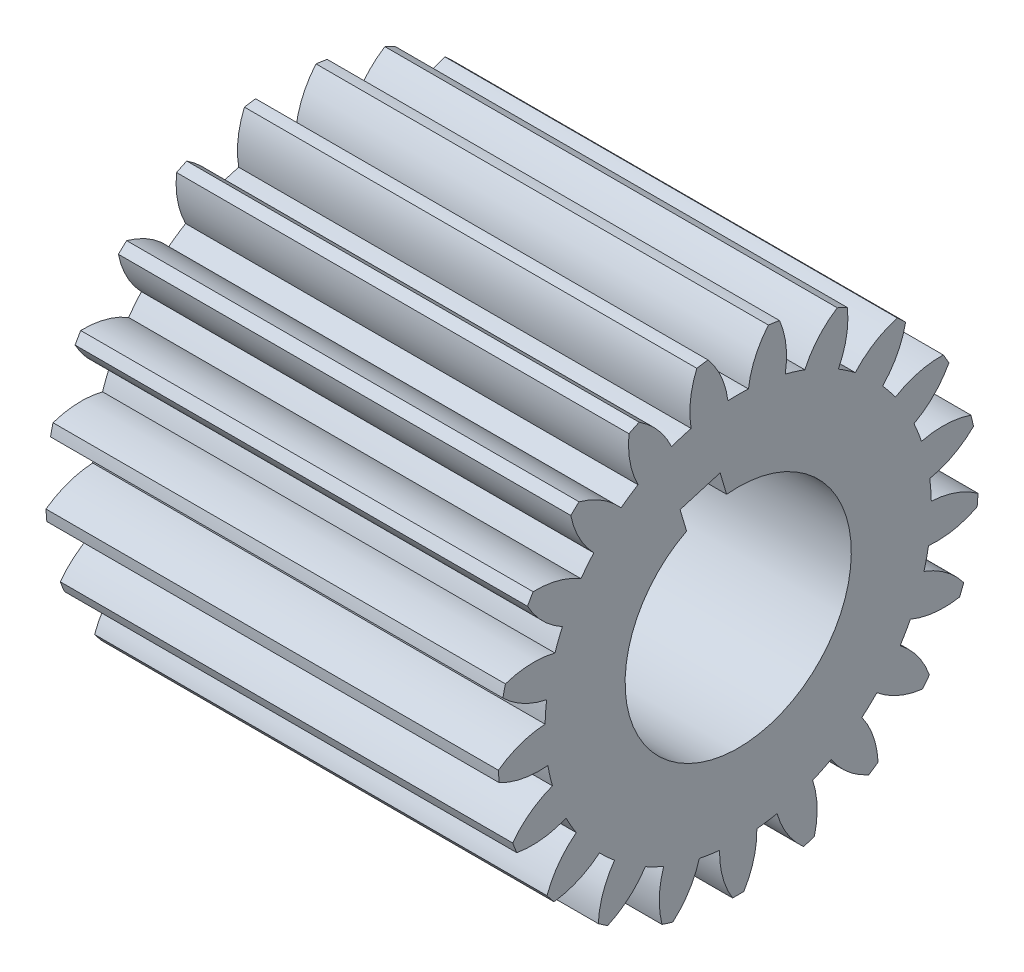
from build123d import *

# Parameters (mm, degrees)
BASPROSKE_W        = 130
BASPROSKE_H        = 69
TOOTHCUT_DEPTH     = 163.548454314
TEETHCUTS_COUNT    = 21
TEETHCUTS_ANGLE    = 342.857142857
BORSKE_R           = 32.5
BORE_DEPTH         = 130.0000508
CUT_EXTRUDE1_DEPTH = 163.509966704


with BuildPart() as part:
    # BasProSke → Base-Revolve (revolve)
    with BuildSketch(Plane(origin=(0, 0, 0), x_dir=(1, 0, 0), z_dir=(0, 1, 0)), mode=Mode.PRIVATE) as base_revolve_sk:
        with Locations((65, 34.5)):
            Rectangle(BASPROSKE_W, BASPROSKE_H)
    revolve(base_revolve_sk.sketch.rotate(Axis((-10, 0, 0), (1, 0, 0)), 180), axis=Axis((-10, 0, 0), (1, 0, 0)))

    # TooCutSke → ToothCut (cut, through all)
    with BuildSketch(Plane(origin=(0, 0, 0), x_dir=(0, 0, -1), z_dir=(1, 0, 0))):
        with BuildLine():
            ThreePointArc((2.93985266, 55.421081434), (0, 55.499), (-2.93985266, 55.421081434))
            ThreePointArc((-2.93985266, 55.421081434), (-4.874938915, 62.364127365), (-8.696301499, 68.475398395))
            ThreePointArc((-8.696301499, 68.475398395), (0, 69.0254), (8.696301499, 68.475398395))
            ThreePointArc((8.696301499, 68.475398395), (4.874938915, 62.364127365), (2.93985266, 55.421081434))
        make_face()
    toothcut = extrude(amount=TOOTHCUT_DEPTH, mode=Mode.SUBTRACT)

    # TeethCuts: ToothCut ×21 about axis
    teethcuts_axis = Axis((-10, 0, 0), (1, 0, 0))
    for i in range(1, TEETHCUTS_COUNT):
        add(toothcut.rotate(teethcuts_axis, i * TEETHCUTS_ANGLE / (TEETHCUTS_COUNT - 1)), mode=Mode.SUBTRACT)

    # BorSke → Bore (cut, symmetric)
    with BuildSketch(Plane(origin=(0, 0, 0), x_dir=(0, 0, -1), z_dir=(1, 0, 0))):
        with Locations(Location((0, 0, 0), (0, 0, 180))):
            Circle(BORSKE_R)
    extrude(amount=BORE_DEPTH, both=True, mode=Mode.SUBTRACT)

    # Sketch1 → Cut-Extrude1 (cut, through all)
    with BuildSketch(Plane.ZY):
        Polygon((16.6951355, 35.206852325), (13.284459239, 23.701754001), (1.779360915, 27.112430262), (5.190037177, 38.617528586), align=None)
    extrude(amount=-CUT_EXTRUDE1_DEPTH, mode=Mode.SUBTRACT)


solid = part.part
